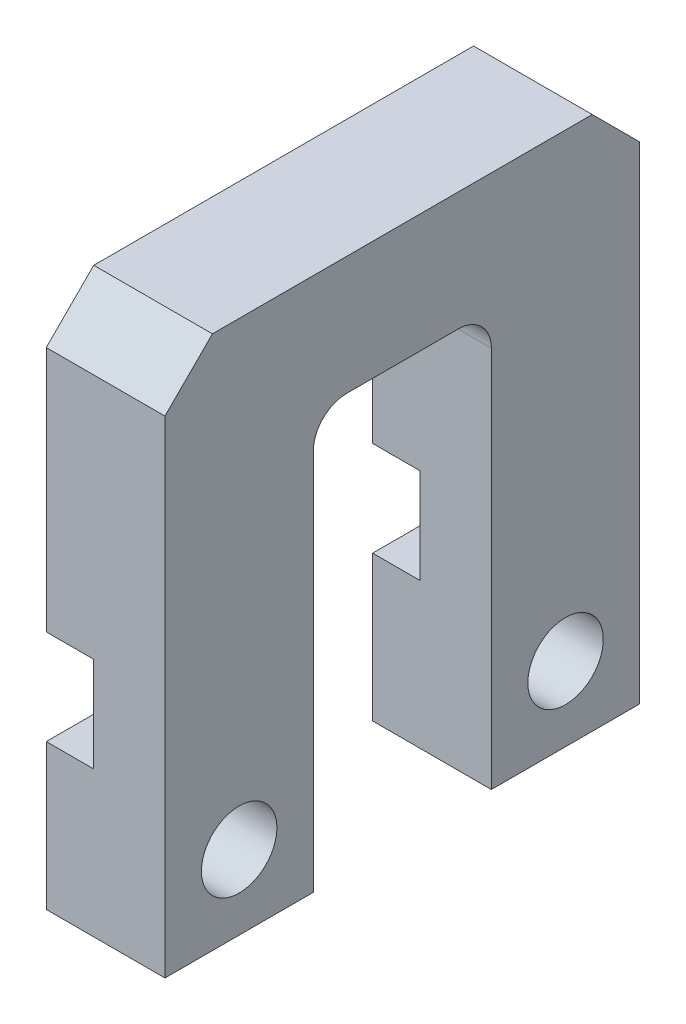
from build123d import *

# Parameters (mm, degrees)
BOSS_EXTRUDE1_DEPTH    = 6.35
F_10_32_TAPPED_HOLE1_D = 4.0386
SKETCH2_W              = 25.4
SKETCH2_H              = 5.08
CUT_EXTRUDE1_DEPTH     = 2.54
CHAMFER1_SIZE          = 2.54


with BuildPart() as part:
    # Sketch1 → Boss-Extrude1 (new body)
    with BuildSketch(Plane(origin=(0, 0, 0), x_dir=(0, 0, -1), z_dir=(1, 0, 0))):
        with BuildLine():
            Line((7.9375, 0), (7.9375, 20.447))
            ThreePointArc((7.9375, 20.447), (8.458264143, 21.704235857), (9.7155, 22.225))
            Line((9.7155, 22.225), (15.6845, 22.225))
            ThreePointArc((15.6845, 22.225), (16.941735857, 21.704235857), (17.4625, 20.447))
            Line((17.4625, 20.447), (17.4625, 0))
            Line((17.4625, 0), (25.4, 0))
            Line((25.4, 0), (25.4, 28.575))
            Line((25.4, 28.575), (0, 28.575))
            Line((0, 28.575), (0, 0))
            Line((0, 0), (7.9375, 0))
        make_face()
    extrude(amount=BOSS_EXTRUDE1_DEPTH)

    # #10-32 Tapped Hole1 (through all)
    with Locations(Plane.ZY):
        with Locations((-21.43125, 3.96875), (-3.96875, 3.96875)):
            Hole(F_10_32_TAPPED_HOLE1_D / 2)

    # Sketch2 → Cut-Extrude1 (cut)
    with BuildSketch(Plane.ZY):
        with Locations((-12.7, 10.31875)):
            Rectangle(SKETCH2_W, SKETCH2_H)
    extrude(amount=-CUT_EXTRUDE1_DEPTH, mode=Mode.SUBTRACT)

    # Chamfer1
    chamfer1_edges = [part.edges().sort_by_distance(p)[0] for p in [
        (3.175, 28.575, 0),
        (3.175, 28.575, -25.4),
    ]]
    chamfer(chamfer1_edges, length=CHAMFER1_SIZE)


solid = part.part
